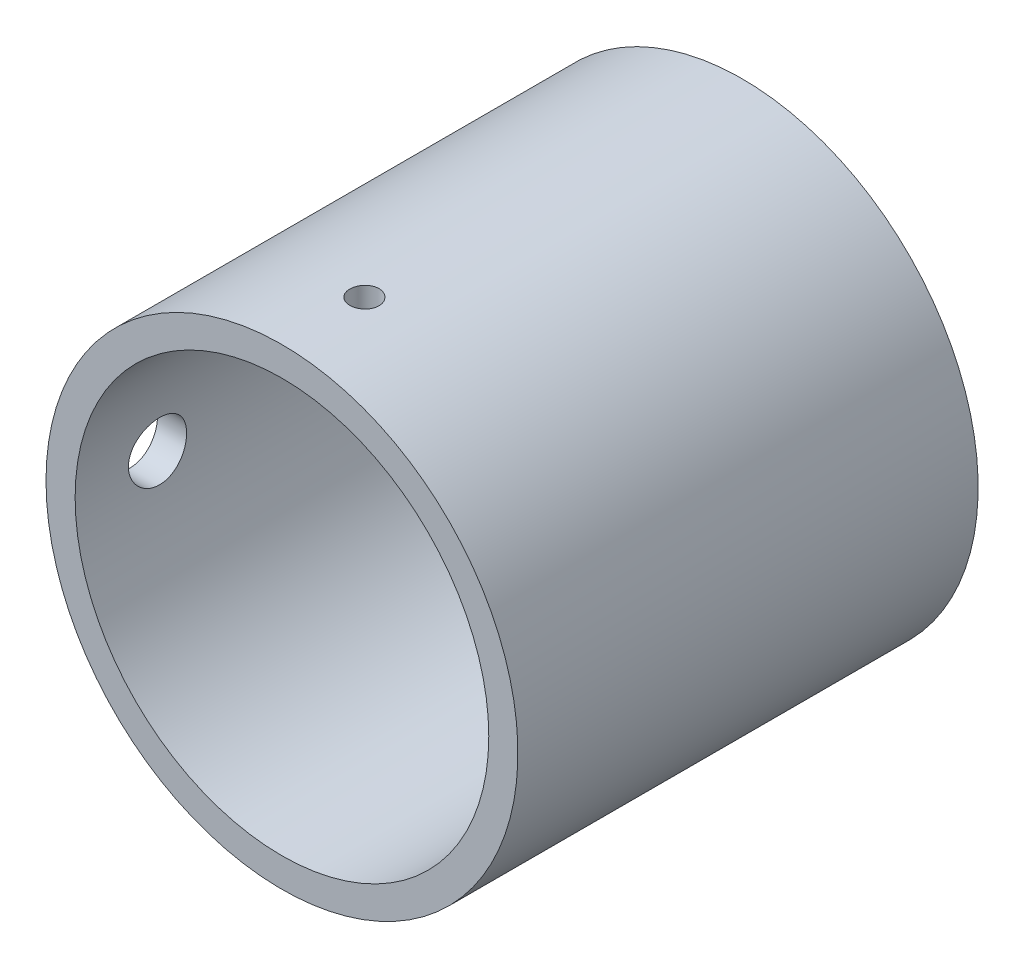
from build123d import *

# Parameters (mm, degrees)
SKETCH1_R                = 8.1
SKETCH1_R_2              = 7.1
BOSS_EXTRUDE1_DEPTH      = 1.3875
BOSS_EXTRUDE1_DEPTH_BACK = 14.4125
SKETCH3_R                = 1
CUT_EXTRUDE1_DEPTH       = 9.1
SKETCH4_R                = 0.5
CUT_EXTRUDE2_DEPTH       = 9.1000001


with BuildPart() as part:
    # Sketch1 → Boss-Extrude1 (new body, two sides)
    with BuildSketch(Plane.XY) as boss_extrude1_sk:
        Circle(SKETCH1_R)
        Circle(SKETCH1_R_2, mode=Mode.SUBTRACT)
    extrude(amount=BOSS_EXTRUDE1_DEPTH)
    extrude(boss_extrude1_sk.sketch, amount=-BOSS_EXTRUDE1_DEPTH_BACK)

    # Sketch3 → Cut-Extrude1 (cut, through all)
    with BuildSketch(Plane(origin=(0, 0, 0), x_dir=(0, 0, -1), z_dir=(1, 0, 0))):
        with Locations((1.440651468, 0)):
            Circle(SKETCH3_R)
    extrude(amount=-CUT_EXTRUDE1_DEPTH, mode=Mode.SUBTRACT)

    # Sketch4 → Cut-Extrude2 (cut, through all)
    with BuildSketch(Plane(origin=(0, 0, 0), x_dir=(1, 0, 0), z_dir=(0, 1, 0))):
        with Locations((0, 1.440651468)):
            Circle(SKETCH4_R)
    extrude(amount=CUT_EXTRUDE2_DEPTH, mode=Mode.SUBTRACT)


solid = part.part
